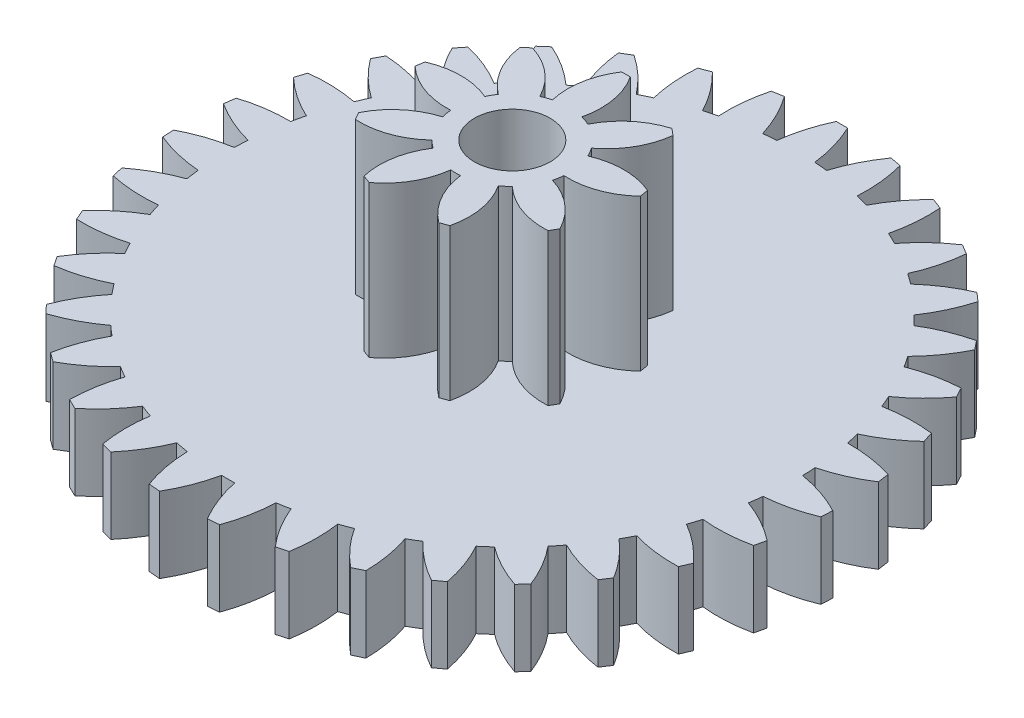
from build123d import *

# Parameters (mm, degrees)
SKETCH1_R               = 7.5
BOSS_EXTRUDE1_DEPTH     = 2
BOSS_EXTRUDE2_DEPTH     = 2
CIRPATTERN1_COUNT       = 35
SKETCH3_R               = 1.5
BOSS_EXTRUDE3_DEPTH     = 4
BOSS_EXTRUDE4_DEPTH     = 4
CIRPATTERN2_COUNT       = 9
SKETCH5_R               = 1
CUT_EXTRUDE1_DEPTH      = 1
CUT_EXTRUDE1_DEPTH_BACK = 7
SKETCH6_R               = 1.5
SKETCH6_R_2             = 1
BOSS_EXTRUDE5_DEPTH     = 0.4


with BuildPart() as part:
    # Sketch1 → Boss-Extrude1 (new body)
    with BuildSketch(Plane(origin=(0, 0, 0), x_dir=(1, 0, 0), z_dir=(0, 1, 0))):
        Circle(SKETCH1_R)
    extrude(amount=BOSS_EXTRUDE1_DEPTH)

    # Sketch2 → Boss-Extrude2 (add)
    with BuildSketch(Plane(origin=(0, 2, 0), x_dir=(1, 0, 0), z_dir=(0, 1, 0))):
        with BuildLine():
            Line((-0.15, 8.7), (0.15, 8.7))
            ThreePointArc((0.15, 8.7), (0.37344133, 8.105592351), (0.5, 7.483314774))
            ThreePointArc((0.5, 7.483314774), (0, 7.5), (-0.5, 7.483314774))
            ThreePointArc((-0.5, 7.483314774), (-0.37344133, 8.105592351), (-0.15, 8.7))
        make_face()
    boss_extrude2 = extrude(amount=-BOSS_EXTRUDE2_DEPTH)

    # CirPattern1: Boss-Extrude2 ×35 about axis
    cirpattern1_axis = Axis((0, 0, 0), (0, 1, 0))
    for i in range(1, CIRPATTERN1_COUNT):
        add(boss_extrude2.rotate(cirpattern1_axis, i * 360 / CIRPATTERN1_COUNT))

    # Sketch3 → Boss-Extrude3 (add)
    with BuildSketch(Plane(origin=(0, 2, 0), x_dir=(1, 0, 0), z_dir=(0, 1, 0))):
        Circle(SKETCH3_R)
    extrude(amount=BOSS_EXTRUDE3_DEPTH)

    # Sketch4 → Boss-Extrude4 (add)
    with BuildSketch(Plane(origin=(0, 6, 0), x_dir=(1, 0, 0), z_dir=(0, 1, 0))):
        with BuildLine():
            Line((-0.115, 3), (0.115, 3))
            ThreePointArc((0.115, 3), (0.410727748, 2.252472239), (0.388228568, 1.448888739))
            ThreePointArc((0.388228568, 1.448888739), (0, 1.5), (-0.388228568, 1.448888739))
            ThreePointArc((-0.388228568, 1.448888739), (-0.410727748, 2.252472239), (-0.115, 3))
        make_face()
    boss_extrude4 = extrude(amount=-BOSS_EXTRUDE4_DEPTH)

    # CirPattern2: Boss-Extrude4 ×9 about axis
    cirpattern2_axis = Axis((0, 0, 0), (0, 1, 0))
    for i in range(1, CIRPATTERN2_COUNT):
        add(boss_extrude4.rotate(cirpattern2_axis, i * 360 / CIRPATTERN2_COUNT))

    # Sketch5 → Cut-Extrude1 (cut, two sides)
    with BuildSketch(Plane(origin=(0, 6, 0), x_dir=(1, 0, 0), z_dir=(0, 1, 0))) as cut_extrude1_sk:
        Circle(SKETCH5_R)
    extrude(amount=CUT_EXTRUDE1_DEPTH, mode=Mode.SUBTRACT)
    extrude(cut_extrude1_sk.sketch, amount=-CUT_EXTRUDE1_DEPTH_BACK, mode=Mode.SUBTRACT)

    # Sketch6 → Boss-Extrude5 (add)
    with BuildSketch(Plane.XZ):
        Circle(SKETCH6_R)
        Circle(SKETCH6_R_2, mode=Mode.SUBTRACT)
    extrude(amount=BOSS_EXTRUDE5_DEPTH)


solid = part.part
